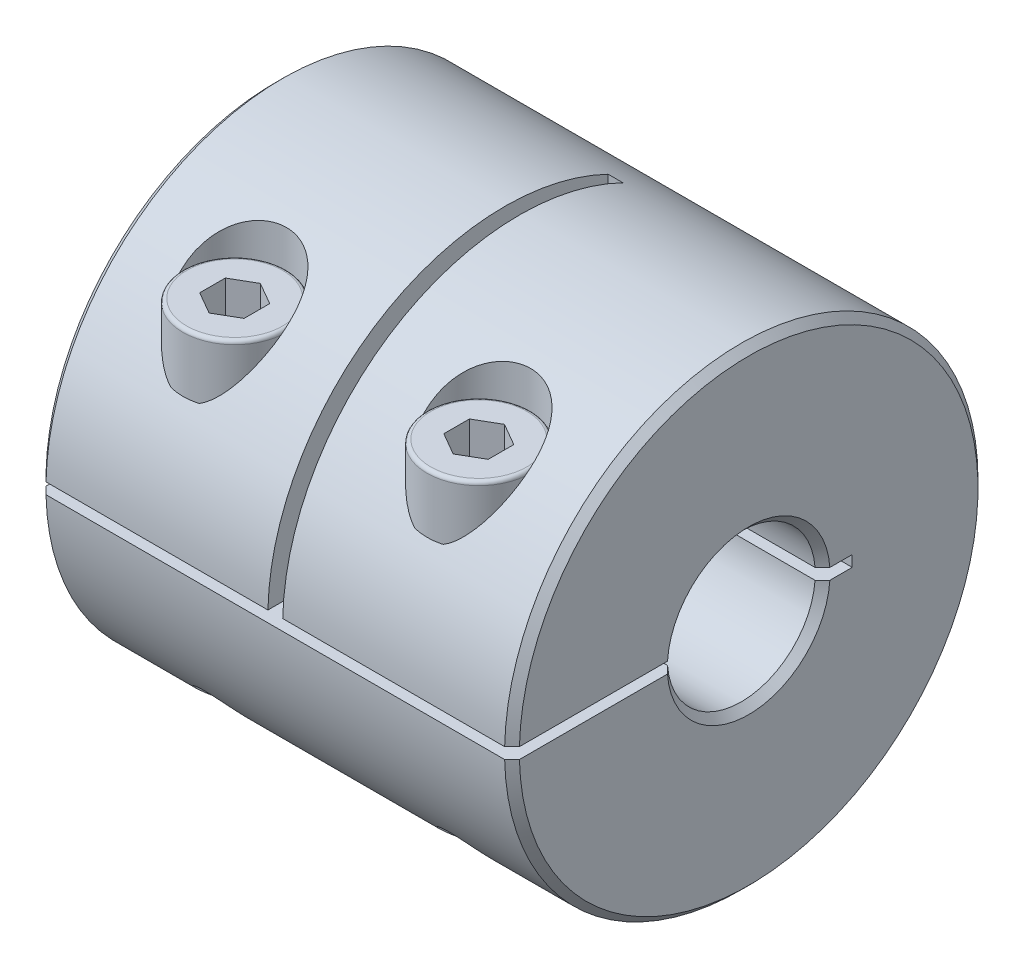
from build123d import *

# Parameters (mm, degrees)
SKETCH1_R           = 16
BOSS_EXTRUDE1_DEPTH = 16
SKETCH2_R           = 5
CUT_EXTRUDE1_DEPTH  = 33
CUT_EXTRUDE2_DEPTH  = 33
SKETCH6_W           = 1
SKETCH6_H           = 16.375
CUT_EXTRUDE3_DEPTH  = 23.995604865
CUT_EXTRUDE4_START  = -16.625
SKETCH7_R           = 2
CUT_EXTRUDE4_DEPTH  = 34
SKETCH8_R           = 3.5
CUT_EXTRUDE5_DEPTH  = 9.0000001
SKETCH9_R           = 3.5
BOSS_EXTRUDE2_DEPTH = 4
SKETCH10_R          = 2
BOSS_EXTRUDE3_DEPTH = 20
FILLET1_R           = 0.25
CUT_EXTRUDE6_DEPTH  = 3
CHAMFER1_SIZE       = 0.5


with BuildPart() as part:
    # Sketch1 → Boss-Extrude1 (new body, symmetric)
    with BuildSketch(Plane(origin=(0, 0, 0), x_dir=(0, 0, -1), z_dir=(1, 0, 0))):
        Circle(SKETCH1_R)
    extrude(amount=BOSS_EXTRUDE1_DEPTH, both=True)

    # Sketch2 → Cut-Extrude1 (cut, through all)
    with BuildSketch(Plane(origin=(16, 0, 0), x_dir=(0, 0, -1), z_dir=(1, 0, 0))):
        Circle(SKETCH2_R)
    extrude(amount=-CUT_EXTRUDE1_DEPTH, mode=Mode.SUBTRACT)

    # Sketch5 → Cut-Extrude2 (cut, through all)
    with BuildSketch(Plane(origin=(16, 0, 0), x_dir=(0, 0, -1), z_dir=(1, 0, 0))):
        with BuildLine():
            Line((-15.995604865, 0.375), (7, 0.375))
            Line((7, 0.375), (7, -0.375))
            Line((7, -0.375), (-15.995604865, -0.375))
            ThreePointArc((-15.995604865, -0.375), (-16, 0), (-15.995604865, 0.375))
        make_face()
    extrude(amount=-CUT_EXTRUDE2_DEPTH, mode=Mode.SUBTRACT)

    # Sketch6 → Cut-Extrude3 (cut, through all)
    with BuildSketch(Plane.XY.offset(-7)):
        with Locations((0, 7.8125)):
            Rectangle(SKETCH6_W, SKETCH6_H)
    extrude(amount=CUT_EXTRUDE3_DEPTH, mode=Mode.SUBTRACT)

    # Sketch7 → Cut-Extrude4 (cut)
    with BuildSketch(Plane(origin=(0, -0.375, 0), x_dir=(1, 0, 0), z_dir=(0, 1, 0)).offset(CUT_EXTRUDE4_START)):
        with Locations(Location((8.25, -10.490761267, 0), (0, 0, 270))):  # turned: the seam where the file's is
            Circle(SKETCH7_R)
    cut_extrude4 = extrude(amount=CUT_EXTRUDE4_DEPTH, mode=Mode.SUBTRACT)

    # Sketch8 → Cut-Extrude5 (cut, through all)
    with BuildSketch(Plane(origin=(0, 8, 0), x_dir=(-1, 0, 0), z_dir=(0, 1, 0))):
        with Locations((-8.25, 10.490761267)):
            Circle(SKETCH8_R)
    cut_extrude5 = extrude(amount=CUT_EXTRUDE5_DEPTH, mode=Mode.SUBTRACT)

    # Mirror1: Cut-Extrude4, Cut-Extrude5 across plane
    add(cut_extrude4.mirror(Plane(origin=(0, 0, 0), x_dir=(0, 0, 1), z_dir=(1, 0, 0))), mode=Mode.SUBTRACT)
    add(cut_extrude5.mirror(Plane(origin=(0, 0, 0), x_dir=(0, 0, 1), z_dir=(1, 0, 0))), mode=Mode.SUBTRACT)

    # Chamfer1
    chamfer1_edges = [part.edges().sort_by_distance(p)[0] for p in [
        (-16, -5, 0),
        (16, -5, 0),
        (-16, 0, -16),
        (16, 0, -16),
        (-16, 5, 0),
        (16, 5, 0),
    ]]
    chamfer(chamfer1_edges, length=CHAMFER1_SIZE)


with BuildPart() as body_2:
    # Sketch9 → Boss-Extrude2 (new body)
    with BuildSketch(Plane(origin=(0, 8, 0), x_dir=(1, 0, 0), z_dir=(0, 1, 0))):
        with Locations(Location((8.25, -10.490761267, 0), (0, 0, 270))):  # turned: the seam where the file's is
            Circle(SKETCH9_R)
    extrude(amount=BOSS_EXTRUDE2_DEPTH)

    # Sketch10 → Boss-Extrude3 (add)
    with BuildSketch(Plane(origin=(0, 12, 0), x_dir=(1, 0, 0), z_dir=(0, 1, 0))):
        with Locations(Location((8.25, -10.490761267, 0), (0, 0, 270))):  # turned: the seam where the file's is
            Circle(SKETCH10_R)
    extrude(amount=-BOSS_EXTRUDE3_DEPTH)

    # Fillet1
    fillet1_edges = [body_2.edges().sort_by_distance(p)[0] for p in [
        (8.25, 12, 6.990761267),
        (8.25, -8, 8.490761267),
    ]]
    fillet(fillet1_edges, radius=FILLET1_R)

    # Sketch11 → Cut-Extrude6 (cut)
    with BuildSketch(Plane(origin=(0, 12, 0), x_dir=(1, 0, 0), z_dir=(0, 1, 0))):
        Polygon((8.25, -8.758710459), (6.75, -9.624735863), (6.75, -11.356786671), (8.25, -12.222812075), (9.75, -11.356786671), (9.75, -9.624735863), align=None)
    extrude(amount=-CUT_EXTRUDE6_DEPTH, mode=Mode.SUBTRACT)


with BuildPart() as body_3:
    # Mirror2: mirrored copy
    add(body_2.part.mirror(Plane(origin=(0, 0, 0), x_dir=(0, 0, 1), z_dir=(1, 0, 0))))


solid = Compound([part.part, body_2.part, body_3.part])
